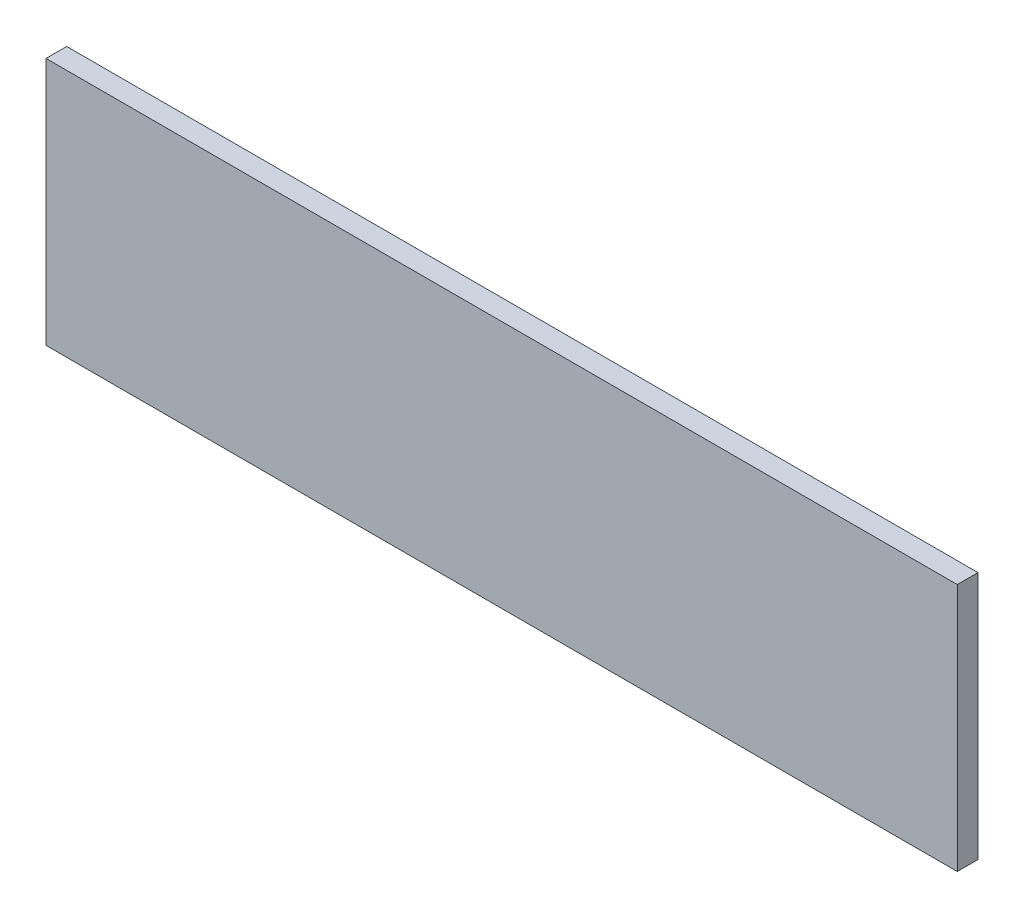
from build123d import *

# Parameters (mm, degrees)
SKETCH1_W           = 279.4
SKETCH1_H           = 76.2
BOSS_EXTRUDE1_DEPTH = 6.35


with BuildPart() as part:
    # Sketch1 → Boss-Extrude1 (new body)
    with BuildSketch(Plane.XY):
        with Locations((139.7, 38.1)):
            Rectangle(SKETCH1_W, SKETCH1_H)
    extrude(amount=BOSS_EXTRUDE1_DEPTH)


solid = part.part
